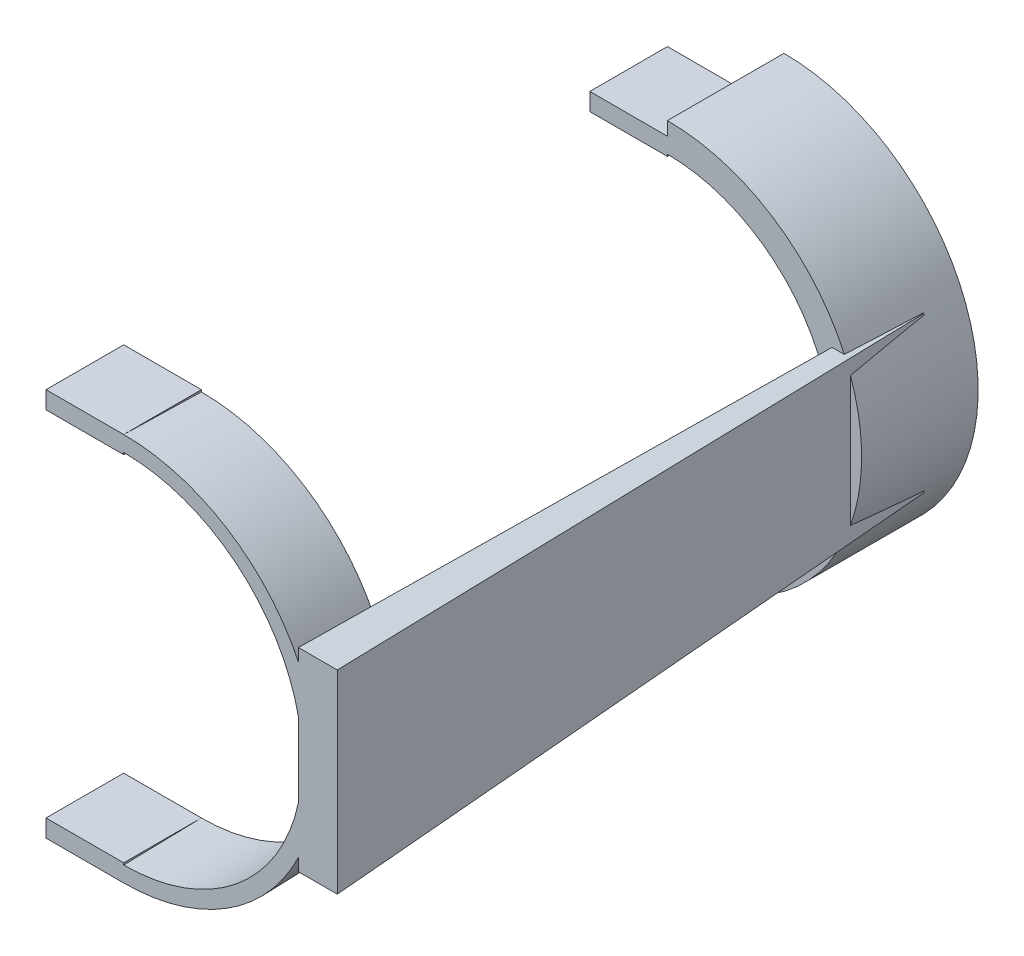
from build123d import *

# Parameters (mm, degrees)
REVOLVE_1_ANGLE     = 180
SKETCH_2_W          = 120
SKETCH_2_H          = 124.466444362
CUT_EXTRUDE_1_DEPTH = 51
SKETCH_3_W          = 10
SKETCH_3_H          = 50
SKETCH_4_W          = 4
SKETCH_4_H          = 40
SKETCH_6_W          = 20
SKETCH_6_H          = 4.5
EXTRUDE_1_DEPTH     = 20
EXTRUDE_3_DEPTH     = 30


with BuildPart() as part:
    # 草图1 → 旋转1 (revolve)
    with BuildSketch(Plane(origin=(0, 0, 0), x_dir=(0, 0, -1), z_dir=(1, 0, 0))):
        Polygon((0, 50), (0, 46), (160, 42), (160, 46), align=None)
    revolve(axis=Axis((0, 0, 0), (0, 0, -1)), revolution_arc=REVOLVE_1_ANGLE)

    # 草图2 → 切除-拉伸1 (cut, through all)
    with BuildSketch(Plane(origin=(0, 0, 0), x_dir=(0, 0, -1), z_dir=(1, 0, 0))):
        with Locations((80, -2.118201403)):
            Rectangle(SKETCH_2_W, SKETCH_2_H)
    extrude(amount=CUT_EXTRUDE_1_DEPTH, mode=Mode.SUBTRACT)

    # 草图3 → 放样1 section 0
    with BuildSketch(Plane.XY):
        with Locations((50, 0)):
            Rectangle(SKETCH_3_W, SKETCH_3_H)
    # 草图4 → 放样1 section 1
    with BuildSketch(Plane(origin=(0, 0, -160), x_dir=(-1, 0, 0), z_dir=(0, 0, -1))):
        with Locations((-44, 0)):
            Rectangle(SKETCH_4_W, SKETCH_4_H)
    loft()

    # 草图6 → 凸台-拉伸1 (add)
    with BuildSketch(Plane.ZY):
        with Locations((-10, 47.75)):
            Rectangle(SKETCH_6_W, SKETCH_6_H)
        with Locations((-10, -47.75)):
            Rectangle(SKETCH_6_W, SKETCH_6_H)
        with Locations((-150, -44.25)):
            Rectangle(SKETCH_6_W, SKETCH_6_H)
        with Locations((-150, 44.25)):
            Rectangle(SKETCH_6_W, SKETCH_6_H)
    extrude(amount=EXTRUDE_1_DEPTH)

    # 草图8 → 凸台-拉伸3 (add)
    with BuildSketch(Plane.XY.offset(-140)):
        with BuildLine():
            Line((0, 46), (0, 50))
            ThreePointArc((0, 50), (50, 0), (0, -50))
            Line((0, -50), (0, -46))
            ThreePointArc((0, -46), (46, 0), (0, 46))
        make_face()
    extrude(amount=-EXTRUDE_3_DEPTH)


solid = part.part
